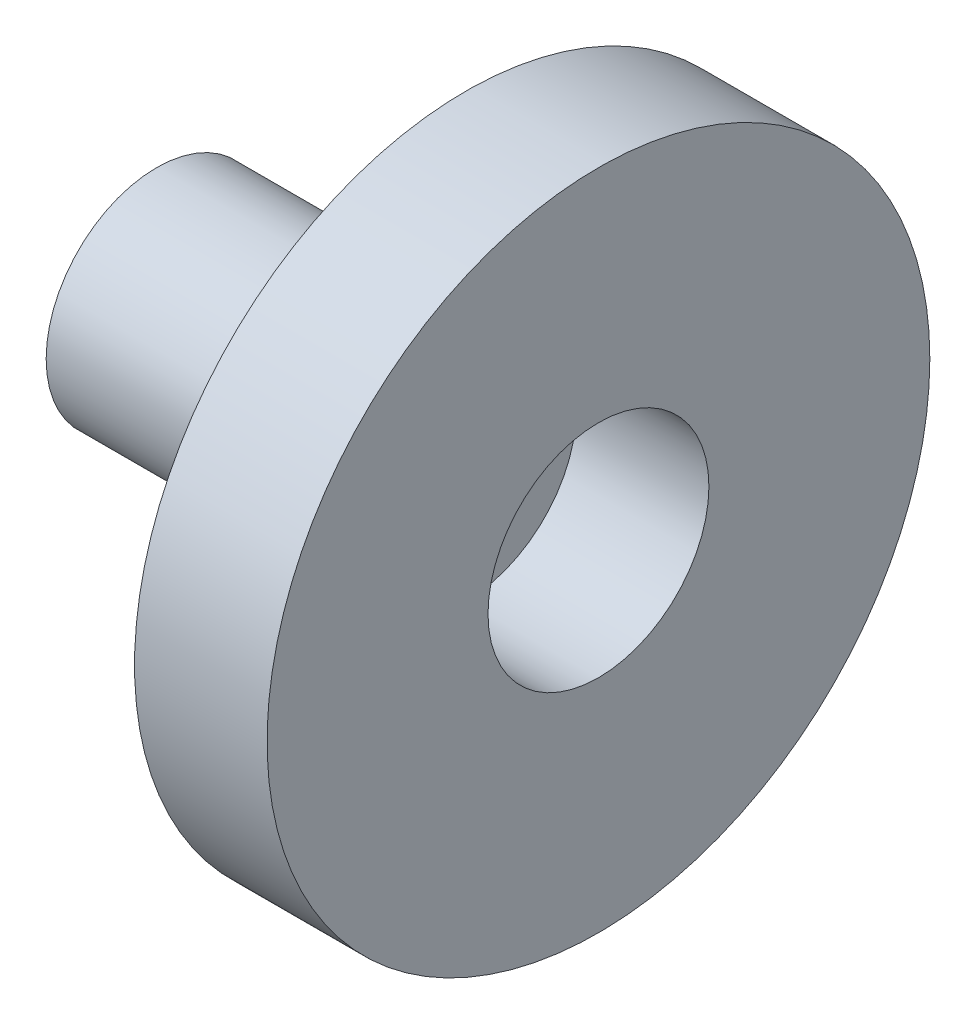
from build123d import *

# Parameters (mm, degrees)
IZIM1_R                     = 15
Y_KSEKLIK_EKSTR_ZYON1_DEPTH = 6
IZIM4_R                     = 6
KES_EKSTR_ZYON2_DEPTH       = 14
KES_EKSTR_ZYON2_DEPTH_BACK  = 14
IZIM2_R                     = 5
Y_KSEKLIK_EKSTR_ZYON2_DEPTH = 14
IZIM5_R                     = 6
IZIM5_R_2                   = 5
Y_KSEKLIK_EKSTR_ZYON3_DEPTH = 6


with BuildPart() as part:
    # izim1 → Y_kseklik-Ekstr_zyon1 (new body)
    with BuildSketch(Plane(origin=(0, 0, 0), x_dir=(0, 0, -1), z_dir=(1, 0, 0))):
        Circle(IZIM1_R)
    extrude(amount=Y_KSEKLIK_EKSTR_ZYON1_DEPTH)

    # izim4 → Kes-Ekstr_zyon2 (cut, two sides)
    with BuildSketch(Plane.ZY) as kes_ekstr_zyon2_sk:
        Circle(IZIM4_R)
    extrude(amount=KES_EKSTR_ZYON2_DEPTH, mode=Mode.SUBTRACT)
    extrude(kes_ekstr_zyon2_sk.sketch, amount=-KES_EKSTR_ZYON2_DEPTH_BACK, mode=Mode.SUBTRACT)

    # izim5 → Y_kseklik-Ekstr_zyon3 (add)
    with BuildSketch(Plane(origin=(6, 0, 0), x_dir=(0, 0, -1), z_dir=(1, 0, 0))):
        Circle(IZIM5_R)
        Circle(IZIM5_R_2, mode=Mode.SUBTRACT)
    extrude(amount=-Y_KSEKLIK_EKSTR_ZYON3_DEPTH)


with BuildPart() as body_2:
    # izim2 → Y_kseklik-Ekstr_zyon2 (new body)
    with BuildSketch(Plane.ZY):
        Circle(IZIM2_R)
    extrude(amount=Y_KSEKLIK_EKSTR_ZYON2_DEPTH)


solid = Compound([part.part, body_2.part])
